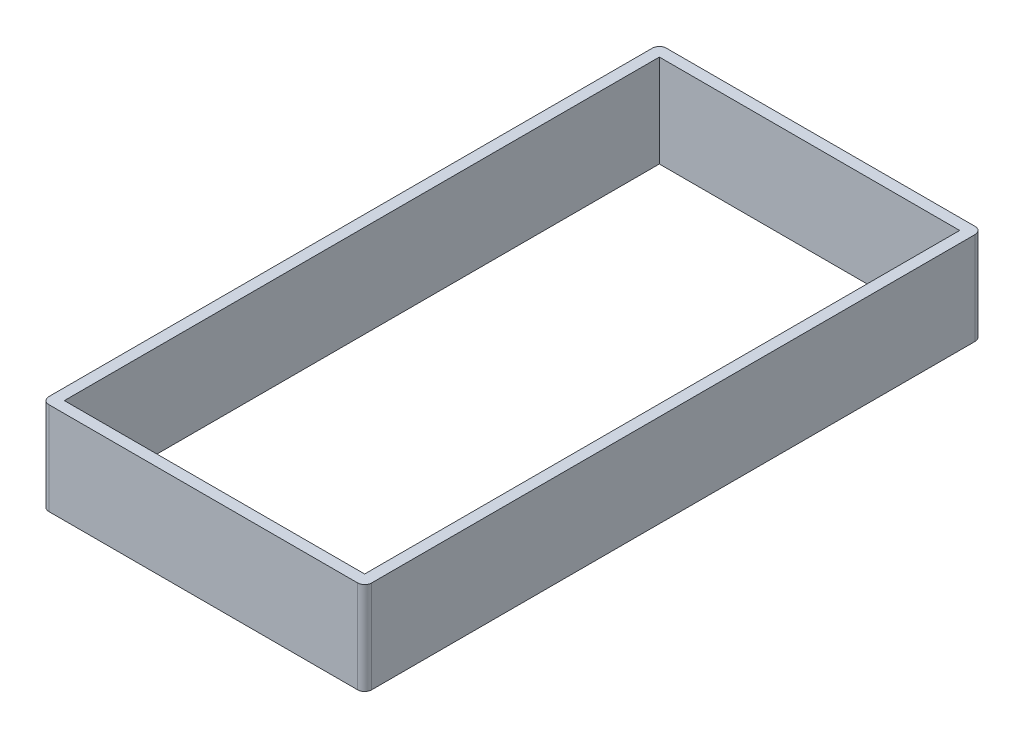
from build123d import *

# Parameters (mm, degrees)
BASES_W            = 23
BASES_H            = 44
BASE_DEPTH         = 3.3
BASE_F_R           = 0.5
POCKETS_W          = 21.4
POCKETS_H          = 42.4
CUT_EXTRUDE3_DEPTH = 26.686767021


with BuildPart() as part:
    # BaseS → BASE (new, symmetric)
    with BuildSketch(Plane(origin=(0, 0, 0), x_dir=(1, 0, 0), z_dir=(0, 1, 0))):
        Rectangle(BASES_W, BASES_H)
    extrude(amount=BASE_DEPTH, both=True)

    # BASE F
    base_f_edges = [part.edges().sort_by_distance(p)[0] for p in [
        (11.5, 0, 22),
        (-11.5, 0, 22),
        (-11.5, 0, -22),
        (11.5, 0, -22),
    ]]
    fillet(base_f_edges, radius=BASE_F_R)

    # PocketS → Cut-Extrude3 (cut, through all)
    with BuildSketch(Plane(origin=(0, 3.3, 0), x_dir=(1, 0, 0), z_dir=(0, 1, 0))):
        Rectangle(POCKETS_W, POCKETS_H)
    extrude(amount=-CUT_EXTRUDE3_DEPTH, mode=Mode.SUBTRACT)


solid = part.part
